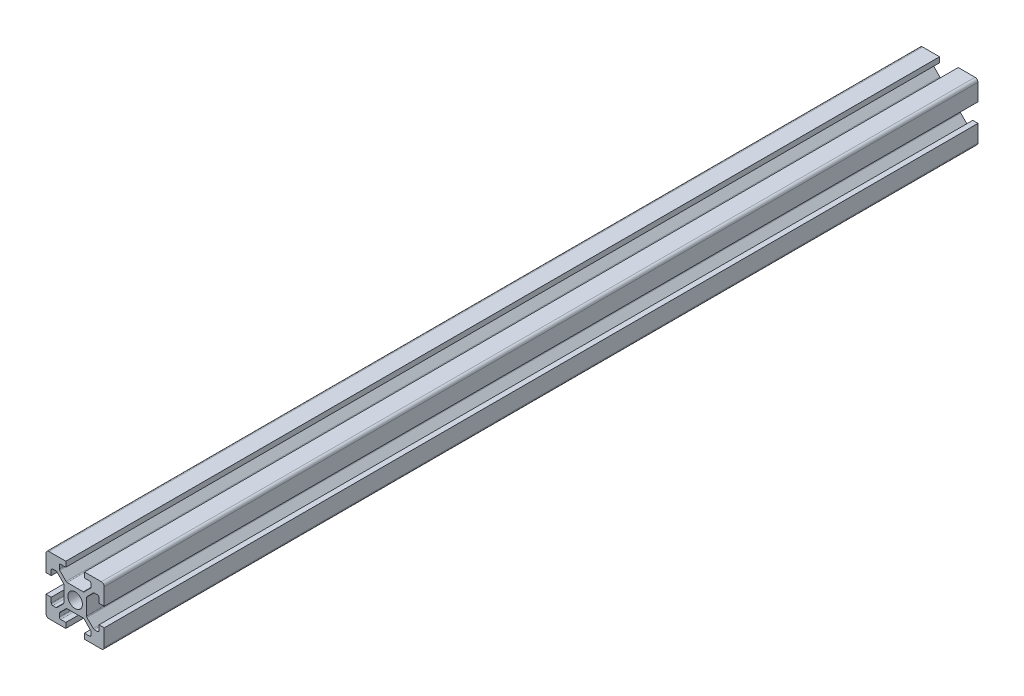
from build123d import *

# Parameters (mm, degrees)
SKETCH1_R           = 2.5
BOSS_EXTRUDE1_DEPTH = 300


with BuildPart() as part:
    # Sketch1 → Boss-Extrude1 (new body)
    with BuildSketch(Plane(origin=(0, 0, 0), x_dir=(-1, 0, 0), z_dir=(0, 0, -1))):
        with BuildLine():
            Line((-20, 19), (-20, 13.2))
            Line((-20, 13.2), (-18.2, 13.2))
            Line((-18.2, 13.2), (-18.2, 14.95))
            ThreePointArc((-18.2, 14.95), (-18.053553391, 15.303553391), (-17.7, 15.45))
            Line((-17.7, 15.45), (-16.607106781, 15.45))
            ThreePointArc((-16.607106781, 15.45), (-16.415765065, 15.411939766), (-16.253553391, 15.303553391))
            Line((-16.253553391, 15.303553391), (-14.046446609, 13.096446609))
            ThreePointArc((-14.046446609, 13.096446609), (-13.938060234, 12.934234935), (-13.9, 12.742893219))
            Line((-13.9, 12.742893219), (-13.9, 7.257106781))
            ThreePointArc((-13.9, 7.257106781), (-13.938060234, 7.065765065), (-14.046446609, 6.903553391))
            Line((-14.046446609, 6.903553391), (-16.253553391, 4.696446609))
            ThreePointArc((-16.253553391, 4.696446609), (-16.415765065, 4.588060234), (-16.607106781, 4.55))
            Line((-16.607106781, 4.55), (-17.7, 4.55))
            ThreePointArc((-17.7, 4.55), (-18.053553391, 4.696446609), (-18.2, 5.05))
            Line((-18.2, 5.05), (-18.2, 6.8))
            Line((-18.2, 6.8), (-20, 6.8))
            Line((-20, 6.8), (-20, 1))
            ThreePointArc((-20, 1), (-19.707106781, 0.292893219), (-19, 0))
            Line((-19, 0), (-13.2, 0))
            Line((-13.2, 0), (-13.2, 1.8))
            Line((-13.2, 1.8), (-14.95, 1.8))
            ThreePointArc((-14.95, 1.8), (-15.303553391, 1.946446609), (-15.45, 2.3))
            Line((-15.45, 2.3), (-15.45, 3.392893219))
            ThreePointArc((-15.45, 3.392893219), (-15.411939766, 3.584234935), (-15.303553391, 3.746446609))
            Line((-15.303553391, 3.746446609), (-13.096446609, 5.953553391))
            ThreePointArc((-13.096446609, 5.953553391), (-12.934234935, 6.061939766), (-12.742893219, 6.1))
            Line((-12.742893219, 6.1), (-7.257106781, 6.1))
            ThreePointArc((-7.257106781, 6.1), (-7.065765065, 6.061939766), (-6.903553391, 5.953553391))
            Line((-6.903553391, 5.953553391), (-4.696446609, 3.746446609))
            ThreePointArc((-4.696446609, 3.746446609), (-4.588060234, 3.584234935), (-4.55, 3.392893219))
            Line((-4.55, 3.392893219), (-4.55, 2.3))
            ThreePointArc((-4.55, 2.3), (-4.696446609, 1.946446609), (-5.05, 1.8))
            Line((-5.05, 1.8), (-6.8, 1.8))
            Line((-6.8, 1.8), (-6.8, 0))
            Line((-6.8, 0), (-1, 0))
            ThreePointArc((-1, 0), (-0.292893219, 0.292893219), (0, 1))
            Line((0, 1), (0, 6.8))
            Line((0, 6.8), (-1.8, 6.8))
            Line((-1.8, 6.8), (-1.8, 5.05))
            ThreePointArc((-1.8, 5.05), (-1.946446609, 4.696446609), (-2.3, 4.55))
            Line((-2.3, 4.55), (-3.392893219, 4.55))
            ThreePointArc((-3.392893219, 4.55), (-3.584234935, 4.588060234), (-3.746446609, 4.696446609))
            Line((-3.746446609, 4.696446609), (-5.953553391, 6.903553391))
            ThreePointArc((-5.953553391, 6.903553391), (-6.061939766, 7.065765065), (-6.1, 7.257106781))
            Line((-6.1, 7.257106781), (-6.1, 12.742893219))
            ThreePointArc((-6.1, 12.742893219), (-6.061939766, 12.934234935), (-5.953553391, 13.096446609))
            Line((-5.953553391, 13.096446609), (-3.746446609, 15.303553391))
            ThreePointArc((-3.746446609, 15.303553391), (-3.584234935, 15.411939766), (-3.392893219, 15.45))
            Line((-3.392893219, 15.45), (-2.3, 15.45))
            ThreePointArc((-2.3, 15.45), (-1.946446609, 15.303553391), (-1.8, 14.95))
            Line((-1.8, 14.95), (-1.8, 13.2))
            Line((-1.8, 13.2), (0, 13.2))
            Line((0, 13.2), (0, 19))
            ThreePointArc((0, 19), (-0.292893219, 19.707106781), (-1, 20))
            Line((-1, 20), (-6.8, 20))
            Line((-6.8, 20), (-6.8, 18.2))
            Line((-6.8, 18.2), (-5.05, 18.2))
            ThreePointArc((-5.05, 18.2), (-4.696446609, 18.053553391), (-4.55, 17.7))
            Line((-4.55, 17.7), (-4.55, 16.607106781))
            ThreePointArc((-4.55, 16.607106781), (-4.588060234, 16.415765065), (-4.696446609, 16.253553391))
            Line((-4.696446609, 16.253553391), (-6.903553391, 14.046446609))
            ThreePointArc((-6.903553391, 14.046446609), (-7.065765065, 13.938060234), (-7.257106781, 13.9))
            Line((-7.257106781, 13.9), (-12.742893219, 13.9))
            ThreePointArc((-12.742893219, 13.9), (-12.934234935, 13.938060234), (-13.096446609, 14.046446609))
            Line((-13.096446609, 14.046446609), (-15.303553391, 16.253553391))
            ThreePointArc((-15.303553391, 16.253553391), (-15.411939766, 16.415765065), (-15.45, 16.607106781))
            Line((-15.45, 16.607106781), (-15.45, 17.7))
            ThreePointArc((-15.45, 17.7), (-15.303553391, 18.053553391), (-14.95, 18.2))
            Line((-14.95, 18.2), (-13.2, 18.2))
            Line((-13.2, 18.2), (-13.2, 20))
            Line((-13.2, 20), (-19, 20))
            ThreePointArc((-19, 20), (-19.707106781, 19.707106781), (-20, 19))
        make_face()
        with Locations((-10, 10)):
            Circle(SKETCH1_R, mode=Mode.SUBTRACT)
    extrude(amount=-BOSS_EXTRUDE1_DEPTH)


solid = part.part
